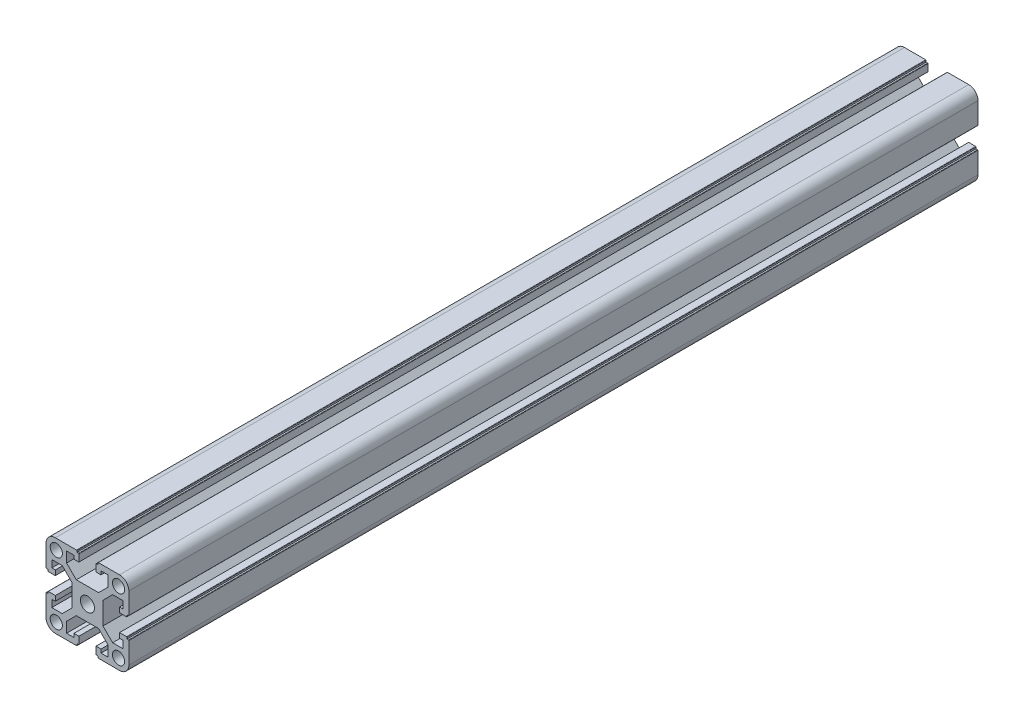
from build123d import *

# Parameters (mm, degrees)
SKETCH_1_R      = 2.95
SKETCH_1_R_2    = 3.4
EXTRUDE_1_DEPTH = 205


with BuildPart() as part:
    # 草图1 → 凸台-拉伸1 (new body, symmetric)
    with BuildSketch(Plane.XY.offset(50)):
        with BuildLine():
            Line((-1518.245004392, 3588.004280474), (-1518.245004392, 3582.975600817))
            Line((-1518.245004392, 3582.975600817), (-1522.916324736, 3578.304280474))
            Line((-1522.916324736, 3578.304280474), (-1533.673684048, 3578.304280474))
            Line((-1533.673684048, 3578.304280474), (-1538.345004392, 3582.975600817))
            Line((-1538.345004392, 3582.975600817), (-1538.345004392, 3588.004280474))
            Line((-1538.345004392, 3588.004280474), (-1534.845004392, 3588.004280474))
            Line((-1534.845004392, 3588.004280474), (-1534.845004392, 3586.304280474))
            Line((-1534.845004392, 3586.304280474), (-1532.445004392, 3586.304280474))
            Line((-1532.445004392, 3586.304280474), (-1532.445004392, 3589.704280474))
            ThreePointArc((-1532.445004392, 3589.704280474), (-1532.503583036, 3589.84570183), (-1532.645004392, 3589.904280474))
            Line((-1532.645004392, 3589.904280474), (-1533.345004392, 3589.904280474))
            Line((-1533.345004392, 3589.904280474), (-1533.345004392, 3590.604280474))
            ThreePointArc((-1533.345004392, 3590.604280474), (-1533.403583036, 3590.74570183), (-1533.545004392, 3590.804280474))
            Line((-1533.545004392, 3590.804280474), (-1543.795004392, 3590.804280474))
            ThreePointArc((-1543.795004392, 3590.804280474), (-1546.976984907, 3589.486260989), (-1548.295004392, 3586.304280474))
            Line((-1548.295004392, 3586.304280474), (-1548.295004392, 3576.054280474))
            ThreePointArc((-1548.295004392, 3576.054280474), (-1548.236425748, 3575.912859117), (-1548.095004392, 3575.854280474))
            Line((-1548.095004392, 3575.854280474), (-1547.395004392, 3575.854280474))
            Line((-1547.395004392, 3575.854280474), (-1547.395004392, 3575.154280474))
            ThreePointArc((-1547.395004392, 3575.154280474), (-1547.336425748, 3575.012859117), (-1547.195004392, 3574.954280474))
            Line((-1547.195004392, 3574.954280474), (-1543.795004392, 3574.954280474))
            Line((-1543.795004392, 3574.954280474), (-1543.795004392, 3577.354280474))
            Line((-1543.795004392, 3577.354280474), (-1545.495004392, 3577.354280474))
            Line((-1545.495004392, 3577.354280474), (-1545.495004392, 3580.854280474))
            Line((-1545.495004392, 3580.854280474), (-1540.466324736, 3580.854280474))
            Line((-1540.466324736, 3580.854280474), (-1535.795004392, 3576.18296013))
            Line((-1535.795004392, 3576.18296013), (-1535.795004392, 3565.425600817))
            Line((-1535.795004392, 3565.425600817), (-1540.466324736, 3560.754280474))
            Line((-1540.466324736, 3560.754280474), (-1545.495004392, 3560.754280474))
            Line((-1545.495004392, 3560.754280474), (-1545.495004392, 3564.254280474))
            Line((-1545.495004392, 3564.254280474), (-1543.795004392, 3564.254280474))
            Line((-1543.795004392, 3564.254280474), (-1543.795004392, 3566.654280474))
            Line((-1543.795004392, 3566.654280474), (-1547.195004392, 3566.654280474))
            ThreePointArc((-1547.195004392, 3566.654280474), (-1547.336425748, 3566.59570183), (-1547.395004392, 3566.454280474))
            Line((-1547.395004392, 3566.454280474), (-1547.395004392, 3565.754280474))
            Line((-1547.395004392, 3565.754280474), (-1548.095004392, 3565.754280474))
            ThreePointArc((-1548.095004392, 3565.754280474), (-1548.236425748, 3565.69570183), (-1548.295004392, 3565.554280474))
            Line((-1548.295004392, 3565.554280474), (-1548.295004392, 3555.304280474))
            ThreePointArc((-1548.295004392, 3555.304280474), (-1546.976984907, 3552.122299958), (-1543.795004392, 3550.804280474))
            Line((-1543.795004392, 3550.804280474), (-1533.545004392, 3550.804280474))
            ThreePointArc((-1533.545004392, 3550.804280474), (-1533.403583036, 3550.862859117), (-1533.345004392, 3551.004280474))
            Line((-1533.345004392, 3551.004280474), (-1533.345004392, 3551.704280474))
            Line((-1533.345004392, 3551.704280474), (-1532.645004392, 3551.704280474))
            ThreePointArc((-1532.645004392, 3551.704280474), (-1532.503583036, 3551.762859117), (-1532.445004392, 3551.904280474))
            Line((-1532.445004392, 3551.904280474), (-1532.445004392, 3555.304280474))
            Line((-1532.445004392, 3555.304280474), (-1534.845004392, 3555.304280474))
            Line((-1534.845004392, 3555.304280474), (-1534.845004392, 3553.604280474))
            Line((-1534.845004392, 3553.604280474), (-1538.345004392, 3553.604280474))
            Line((-1538.345004392, 3553.604280474), (-1538.345004392, 3558.63296013))
            Line((-1538.345004392, 3558.63296013), (-1533.673684048, 3563.304280474))
            Line((-1533.673684048, 3563.304280474), (-1522.916324736, 3563.304280474))
            Line((-1522.916324736, 3563.304280474), (-1518.245004392, 3558.63296013))
            Line((-1518.245004392, 3558.63296013), (-1518.245004392, 3553.604280474))
            Line((-1518.245004392, 3553.604280474), (-1521.745004392, 3553.604280474))
            Line((-1521.745004392, 3553.604280474), (-1521.745004392, 3555.304280474))
            Line((-1521.745004392, 3555.304280474), (-1524.145004392, 3555.304280474))
            Line((-1524.145004392, 3555.304280474), (-1524.145004392, 3551.904280474))
            ThreePointArc((-1524.145004392, 3551.904280474), (-1524.086425748, 3551.762859117), (-1523.945004392, 3551.704280474))
            Line((-1523.945004392, 3551.704280474), (-1523.245004392, 3551.704280474))
            Line((-1523.245004392, 3551.704280474), (-1523.245004392, 3551.004280474))
            ThreePointArc((-1523.245004392, 3551.004280474), (-1523.186425748, 3550.862859117), (-1523.045004392, 3550.804280474))
            Line((-1523.045004392, 3550.804280474), (-1512.795004392, 3550.804280474))
            ThreePointArc((-1512.795004392, 3550.804280474), (-1509.613023877, 3552.122299958), (-1508.295004392, 3555.304280474))
            Line((-1508.295004392, 3555.304280474), (-1508.295004392, 3565.554280474))
            ThreePointArc((-1508.295004392, 3565.554280474), (-1508.353583036, 3565.69570183), (-1508.495004392, 3565.754280474))
            Line((-1508.495004392, 3565.754280474), (-1509.195004392, 3565.754280474))
            Line((-1509.195004392, 3565.754280474), (-1509.195004392, 3566.454280474))
            ThreePointArc((-1509.195004392, 3566.454280474), (-1509.253583036, 3566.59570183), (-1509.395004392, 3566.654280474))
            Line((-1509.395004392, 3566.654280474), (-1512.795004392, 3566.654280474))
            Line((-1512.795004392, 3566.654280474), (-1512.795004392, 3564.254280474))
            Line((-1512.795004392, 3564.254280474), (-1511.095004392, 3564.254280474))
            Line((-1511.095004392, 3564.254280474), (-1511.095004392, 3560.754280474))
            Line((-1511.095004392, 3560.754280474), (-1516.123684048, 3560.754280474))
            Line((-1516.123684048, 3560.754280474), (-1520.795004392, 3565.425600817))
            Line((-1520.795004392, 3565.425600817), (-1520.795004392, 3576.18296013))
            Line((-1520.795004392, 3576.18296013), (-1516.123684048, 3580.854280474))
            Line((-1516.123684048, 3580.854280474), (-1511.095004392, 3580.854280474))
            Line((-1511.095004392, 3580.854280474), (-1511.095004392, 3577.354280474))
            Line((-1511.095004392, 3577.354280474), (-1512.795004392, 3577.354280474))
            Line((-1512.795004392, 3577.354280474), (-1512.795004392, 3574.954280474))
            Line((-1512.795004392, 3574.954280474), (-1509.395004392, 3574.954280474))
            ThreePointArc((-1509.395004392, 3574.954280474), (-1509.253583036, 3575.012859117), (-1509.195004392, 3575.154280474))
            Line((-1509.195004392, 3575.154280474), (-1509.195004392, 3575.854280474))
            Line((-1509.195004392, 3575.854280474), (-1508.495004392, 3575.854280474))
            ThreePointArc((-1508.495004392, 3575.854280474), (-1508.353583036, 3575.912859117), (-1508.295004392, 3576.054280474))
            Line((-1508.295004392, 3576.054280474), (-1508.295004392, 3586.304280474))
            ThreePointArc((-1508.295004392, 3586.304280474), (-1509.613023877, 3589.486260989), (-1512.795004392, 3590.804280474))
            Line((-1512.795004392, 3590.804280474), (-1523.045004392, 3590.804280474))
            ThreePointArc((-1523.045004392, 3590.804280474), (-1523.186425748, 3590.74570183), (-1523.245004392, 3590.604280474))
            Line((-1523.245004392, 3590.604280474), (-1523.245004392, 3589.904280474))
            Line((-1523.245004392, 3589.904280474), (-1523.945004392, 3589.904280474))
            ThreePointArc((-1523.945004392, 3589.904280474), (-1524.086425748, 3589.84570183), (-1524.145004392, 3589.704280474))
            Line((-1524.145004392, 3589.704280474), (-1524.145004392, 3586.304280474))
            Line((-1524.145004392, 3586.304280474), (-1521.745004392, 3586.304280474))
            Line((-1521.745004392, 3586.304280474), (-1521.745004392, 3588.004280474))
            Line((-1521.745004392, 3588.004280474), (-1518.245004392, 3588.004280474))
        make_face()
        with Locations((-1513.270004392, 3555.779280474)):
            Circle(SKETCH_1_R, mode=Mode.SUBTRACT)
        with Locations((-1528.295004392, 3570.804280474)):
            Circle(SKETCH_1_R_2, mode=Mode.SUBTRACT)
        with Locations((-1513.270004392, 3585.829280474)):
            Circle(SKETCH_1_R, mode=Mode.SUBTRACT)
        with Locations((-1543.320004392, 3585.829280474)):
            Circle(SKETCH_1_R, mode=Mode.SUBTRACT)
        with Locations((-1543.320004392, 3555.779280474)):
            Circle(SKETCH_1_R, mode=Mode.SUBTRACT)
    extrude(amount=EXTRUDE_1_DEPTH, both=True)


solid = part.part
